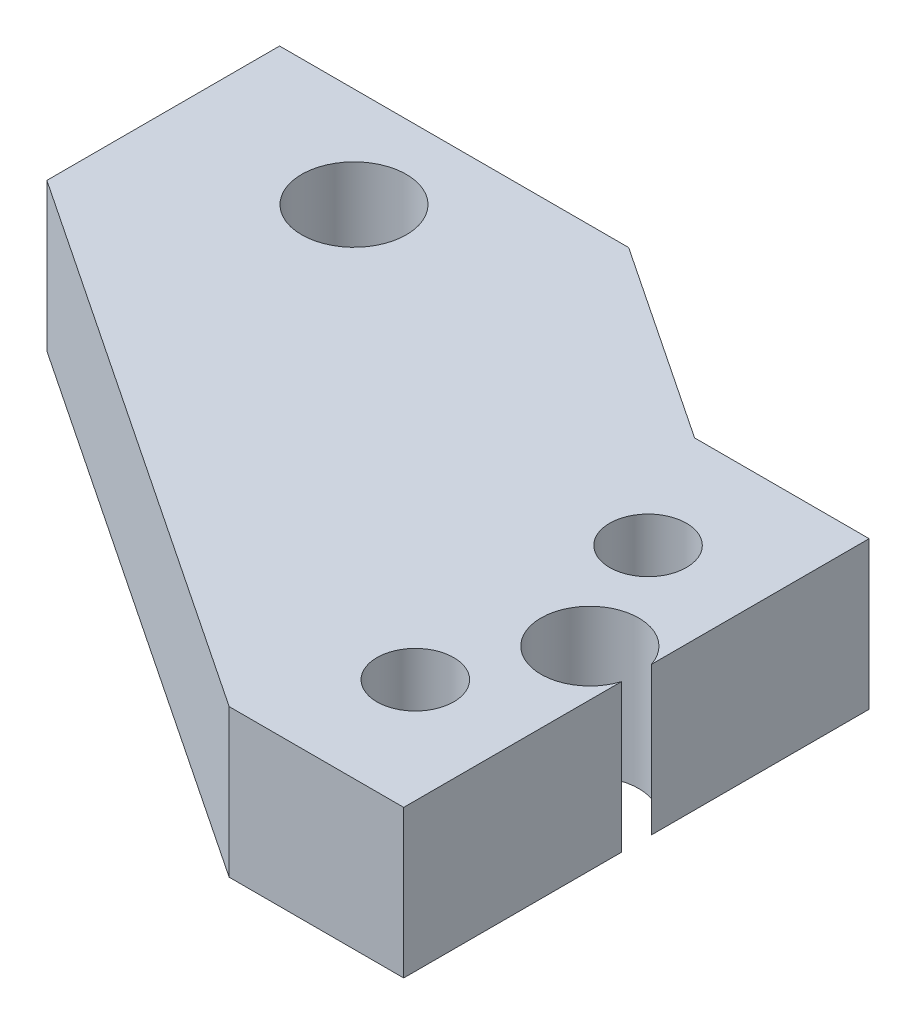
from build123d import *

# Parameters (mm, degrees)
BOSS_EXTRUDE1_DEPTH   = 3.175
M4_CLEARANCE_HOLE1_D  = 4.5
M4X0_7_TAPPED_HOLE1_D = 3.3
M5X0_8_TAPPED_HOLE1_D = 4.2


with BuildPart() as part:
    # Sketch1 → Boss-Extrude1 (new body, symmetric)
    with BuildSketch(Plane(origin=(0, 0, 0), x_dir=(1, 0, 0), z_dir=(0, 1, 0))):
        Polygon((0, 0), (0, 20), (-7.5, 20), (-16, 25.666666667), (-31, 25.666666667), (-31, 15.666666667), (-7.5, 0), align=None)
    extrude(amount=BOSS_EXTRUDE1_DEPTH, both=True)

    # M4 Clearance Hole1 (through all)
    with Locations(Plane(origin=(0, 3.175, 0), x_dir=(1, 0, 0), z_dir=(0, 1, 0))):
        with Locations((-23.5, 21.364471274)):
            Hole(M4_CLEARANCE_HOLE1_D / 2)

    # M4x0.7 Tapped Hole1 (through all)
    with Locations(Plane(origin=(0, 3.175, 0), x_dir=(1, 0, 0), z_dir=(0, 1, 0))):
        with Locations((-4.500000447, 15), (-4.500000447, 5)):
            Hole(M4X0_7_TAPPED_HOLE1_D / 2)

    # M5x0.8 Tapped Hole1 (through all)
    with Locations(Plane(origin=(0, 3.175, 0), x_dir=(1, 0, 0), z_dir=(0, 1, 0))):
        with Locations((-2, 10)):
            Hole(M5X0_8_TAPPED_HOLE1_D / 2)


solid = part.part
